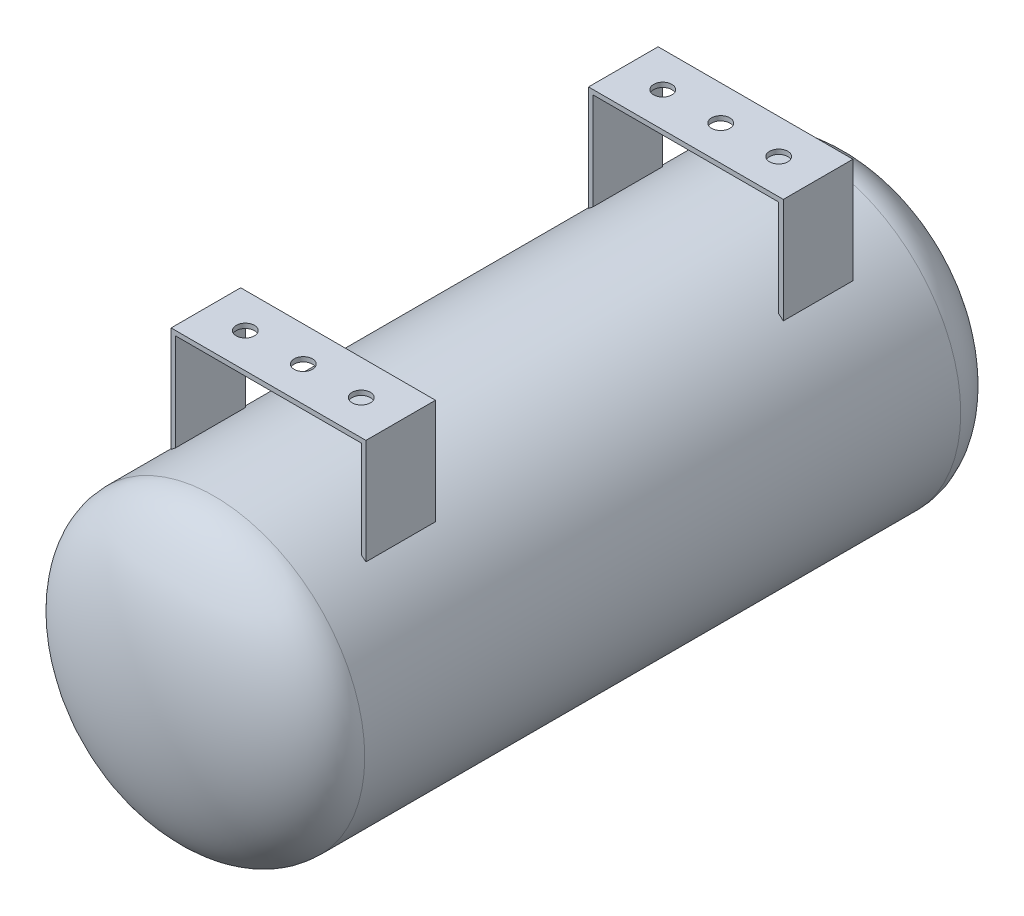
from build123d import *

# Parameters (mm, degrees)
SKETCH6_W             = 106.68
SKETCH6_H             = 38.1
SKETCH6_R             = 5
BOSS_EXTRUDE1_DEPTH   = 2.54
BOSS_EXTRUDE1_2_DEPTH = 2.54
BOSS_EXTRUDE2_START   = -57.647247
SKETCH7_W             = 2.54
SKETCH7_H             = 38.1
BOSS_EXTRUDE2_DEPTH   = 55.107247


with BuildPart() as part:
    # Sketch4 → Revolve1 (revolve)
    with BuildSketch(Plane(origin=(0, 0, 0), x_dir=(1, 0, 0), z_dir=(0, 1, 0))):
        with BuildLine():
            Line((-82.55, -163.195), (-82.55, 163.195))
            add(Edge.make_bspline(
                [(0, 203.835), (-82.55, 203.835), (-82.55, 163.195)],
                knots=[4.71238898, 4.71238898, 4.71238898, 6.283185307, 6.283185307, 6.283185307], degree=2, weights=[1, 0.707106781, 1]))
            Line((0, 203.835), (0, -203.835))
            add(Edge.make_bspline(
                [(-82.55, -163.195), (-82.55, -203.835), (0, -203.835)],
                knots=[0, 0, 0, 1.570796327, 1.570796327, 1.570796327], degree=2, weights=[1, 0.707106781, 1]))
        make_face()
    revolve(axis=Axis((0, 0, 0), (0, 0, -1)))



with BuildPart() as body_2:
    # Sketch6 → Boss-Extrude1 (new body)
    with BuildSketch(Plane(origin=(0, 120.65, 0), x_dir=(1, 0, 0), z_dir=(0, 1, 0))):
        with Locations((0, 114.3)):
            Rectangle(SKETCH6_W, SKETCH6_H)
        with Locations((-31.75, 114.3)):
            Circle(SKETCH6_R, mode=Mode.SUBTRACT)
        with Locations((0, 114.3)):
            Circle(SKETCH6_R, mode=Mode.SUBTRACT)
        with Locations((31.75, 114.3)):
            Circle(SKETCH6_R, mode=Mode.SUBTRACT)
    extrude(amount=-BOSS_EXTRUDE1_DEPTH)


with BuildPart() as body_3:
    # Sketch6 → Boss-Extrude1 2 (new body)
    with BuildSketch(Plane(origin=(0, 120.65, 0), x_dir=(1, 0, 0), z_dir=(0, 1, 0))):
        with Locations((0, -114.3)):
            Rectangle(SKETCH6_W, SKETCH6_H)
        with Locations((31.75, -114.3)):
            Circle(SKETCH6_R, mode=Mode.SUBTRACT)
        with Locations((0, -114.3)):
            Circle(SKETCH6_R, mode=Mode.SUBTRACT)
        with Locations((-31.75, -114.3)):
            Circle(SKETCH6_R, mode=Mode.SUBTRACT)
    extrude(amount=-BOSS_EXTRUDE1_2_DEPTH)


with BuildPart() as part_1:
    add(part.part)

    add(body_2.part)  # Boss-Extrude2 merges body 2

    add(body_3.part)  # Boss-Extrude2 merges body 3
    # Sketch7 → Boss-Extrude2 (add)
    with BuildSketch(Plane(origin=(0, 120.65, 0), x_dir=(1, 0, 0), z_dir=(0, 1, 0)).offset(BOSS_EXTRUDE2_START)):
        with Locations((-52.07, 114.3)):
            Rectangle(SKETCH7_W, SKETCH7_H)
        with Locations((52.07, 114.3)):
            Rectangle(SKETCH7_W, SKETCH7_H)
        with Locations((52.07, -114.3)):
            Rectangle(SKETCH7_W, SKETCH7_H)
        with Locations((-52.07, -114.3)):
            Rectangle(SKETCH7_W, SKETCH7_H)
    extrude(amount=BOSS_EXTRUDE2_DEPTH)


solid = part_1.part
